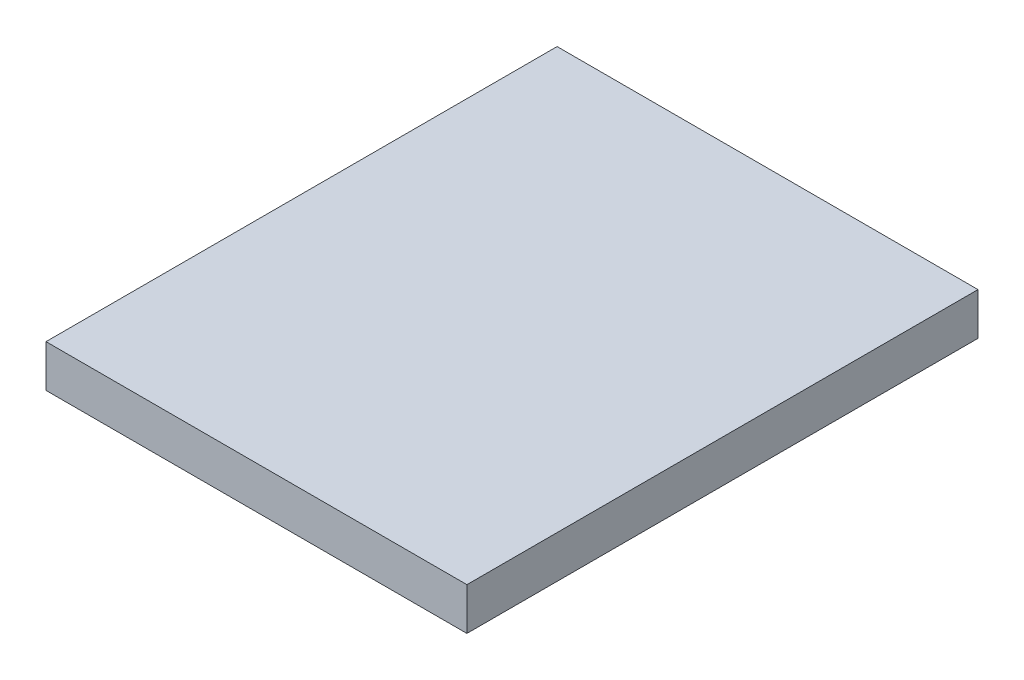
from build123d import *

# Parameters (mm, degrees)
SKETCH1_W           = 127
SKETCH1_H           = 154.21
BOSS_EXTRUDE1_DEPTH = 12.75


with BuildPart() as part:
    # Sketch1 → Boss-Extrude1 (new body)
    with BuildSketch(Plane(origin=(0, 0, 0), x_dir=(1, 0, 0), z_dir=(0, 1, 0))):
        with Locations((63.5, 77.105)):
            Rectangle(SKETCH1_W, SKETCH1_H)
    extrude(amount=BOSS_EXTRUDE1_DEPTH)


solid = part.part
